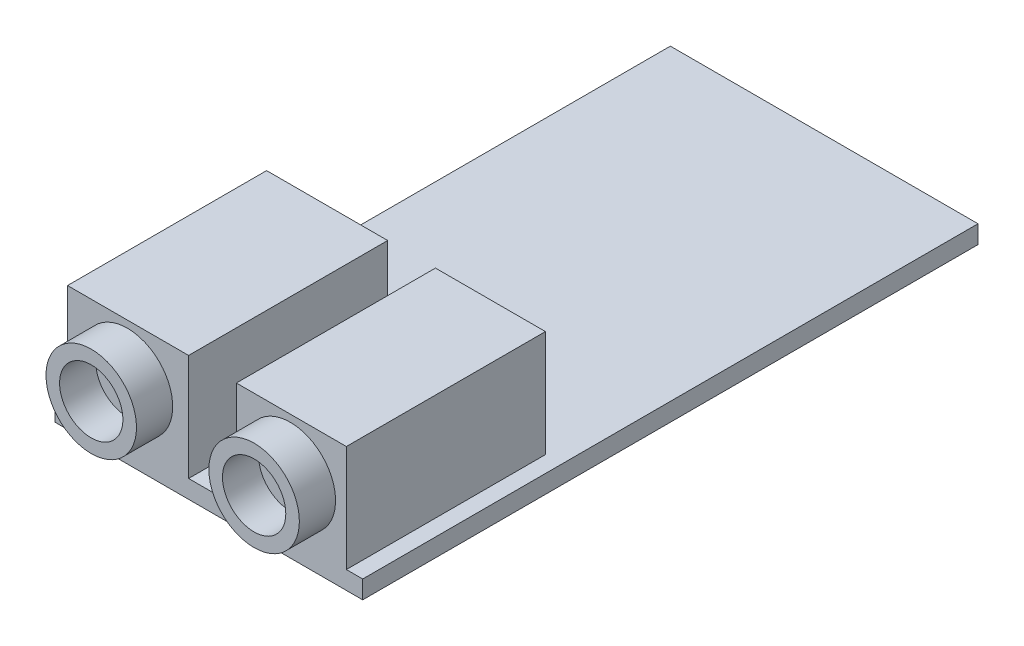
from build123d import *

# Parameters (mm, degrees)
IZIM1_W                       = 17
IZIM1_H                       = 34
Y_KSEKLIK_EKSTR_ZYON1_DEPTH   = 1
IZIM2_R                       = 2.5
IZIM2_R_2                     = 1.75
Y_KSEKLIK_EKSTR_ZYON2_DEPTH   = 2
Y_KSEKLIK_EKSTR_ZYON2_2_DEPTH = 2
IZIM3_W                       = 6.690686046
IZIM3_H                       = 5.888560339
IZIM3_W_2                     = 6.077595292
Y_KSEKLIK_EKSTR_ZYON3_DEPTH   = 11


with BuildPart() as part:
    # Çizim1 → Yükseklik-Ekstrüzyon1 (new body)
    with BuildSketch(Plane(origin=(0, 0, 0), x_dir=(1, 0, 0), z_dir=(0, 1, 0))):
        Rectangle(IZIM1_W, IZIM1_H)
    extrude(amount=Y_KSEKLIK_EKSTR_ZYON1_DEPTH)



with BuildPart() as body_2:
    # Çizim2 → Yükseklik-Ekstrüzyon2 (new body)
    with BuildSketch(Plane.XY.offset(17)):
        with Locations((-4.5, 4)):
            Circle(IZIM2_R)
        with Locations((-4.5, 4)):
            Circle(IZIM2_R_2, mode=Mode.SUBTRACT)
    extrude(amount=Y_KSEKLIK_EKSTR_ZYON2_DEPTH)


with BuildPart() as body_3:
    # Çizim2 → Y_kseklik-Ekstr_zyon2 2 (new body)
    with BuildSketch(Plane.XY.offset(17)):
        with Locations((4.5, 4)):
            Circle(IZIM2_R)
        with Locations((4.5, 4)):
            Circle(IZIM2_R_2, mode=Mode.SUBTRACT)
    extrude(amount=Y_KSEKLIK_EKSTR_ZYON2_2_DEPTH)


with BuildPart() as part_1:
    add(part.part)

    add(body_2.part)  # Yükseklik-Ekstrüzyon3 merges body 2

    add(body_3.part)  # Yükseklik-Ekstrüzyon3 merges body 3
    # Çizim3 → Yükseklik-Ekstrüzyon3 (add)
    with BuildSketch(Plane.XY.offset(17)):
        with Locations((-4.46490005, 3.94428017)):
            Rectangle(IZIM3_W, IZIM3_H)
        with Locations((4.558196469, 3.94428017)):
            Rectangle(IZIM3_W_2, IZIM3_H)
    extrude(amount=-Y_KSEKLIK_EKSTR_ZYON3_DEPTH)


solid = part_1.part
